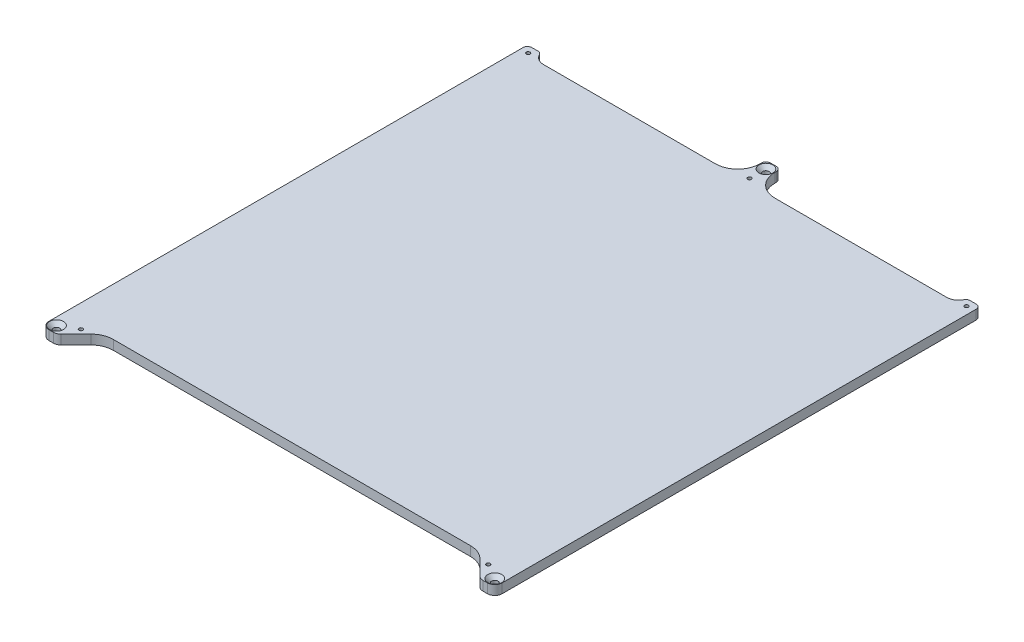
from build123d import *

# Parameters (mm, degrees)
SKETCH1_W                      = 305
SKETCH1_H                      = 327
BOSS_EXTRUDE1_DEPTH            = 6.35
CUT_EXTRUDE1_DEPTH             = 7.35
SKETCH3_W                      = 10
SKETCH3_H                      = 6.35
BOSS_EXTRUDE2_DEPTH            = 19
SKETCH4_W                      = 253
SKETCH4_H                      = 16
CUT_EXTRUDE2_DEPTH             = 7.35
DRAFT1_ANGLE                   = 45
F_4_3_4_3_DIAMETER_HOLE1_D     = 4.3
F_2_5_2_5_DIAMETER_HOLE1_D     = 2.5
F_2_5_2_5_DIAMETER_HOLE1_DEPTH = 6.35
CHAMFER1_SIZE                  = 2.55
FILLET1_R                      = 3
FILLET2_R                      = 5
FILLET3_R                      = 15


with BuildPart() as part:
    # Sketch1 → Boss-Extrude1 (new body)
    with BuildSketch(Plane(origin=(0, 6.35, 0), x_dir=(1, 0, 0), z_dir=(0, 1, 0))):
        with Locations((0, -5)):
            Rectangle(SKETCH1_W, SKETCH1_H)
    extrude(amount=-BOSS_EXTRUDE1_DEPTH)

    # Sketch2 → Cut-Extrude1 (cut, through all)
    with BuildSketch(Plane(origin=(0, 6.35, 0), x_dir=(-1, 0, 0), z_dir=(0, 1, 0))):
        with BuildLine():
            Line((-143.448007721, -158.5), (143.448007721, -158.5))
            ThreePointArc((143.448007721, -158.5), (140.601020514, -154.17544468), (135.702041029, -152.5))
            Line((135.702041029, -152.5), (-135.702041029, -152.5))
            ThreePointArc((-135.702041029, -152.5), (-140.601020514, -154.17544468), (-143.448007721, -158.5))
        make_face()
    extrude(amount=-CUT_EXTRUDE1_DEPTH, mode=Mode.SUBTRACT)

    # Sketch3 → Boss-Extrude2 (add)
    with BuildSketch(Plane(origin=(0, 0, -152.5), x_dir=(-1, 0, 0), z_dir=(0, 0, -1))):
        with Locations((0, 3.175)):
            Rectangle(SKETCH3_W, SKETCH3_H)
    extrude(amount=BOSS_EXTRUDE2_DEPTH)

    # Sketch4 → Cut-Extrude2 (cut, through all)
    with BuildSketch(Plane.XZ):
        with Locations((0, 160.5)):
            Rectangle(SKETCH4_W, SKETCH4_H)
    extrude(amount=-CUT_EXTRUDE2_DEPTH, mode=Mode.SUBTRACT)

    # Draft1
    draft1_faces = [part.faces().sort_by_distance(p)[0] for p in [
        (-126.5, 3.175, 160.5),
        (126.5, 3.175, 160.5),
    ]]
    draft(draft1_faces, Plane(origin=(-126.5, 6.35, 152.5), x_dir=(1, 0, 0), z_dir=(0, 0, 1)), DRAFT1_ANGLE)

    # Ø4.3 (4.3) Diameter Hole1 (through all)
    with Locations(Plane(origin=(0, 6.35, 0), x_dir=(1, 0, 0), z_dir=(0, 1, 0))):
        with Locations((0, 166.5), (-147.5, -163.5), (147.5, -163.5)):
            Hole(F_4_3_4_3_DIAMETER_HOLE1_D / 2)

    # Ø2.5 (2.5) Diameter Hole1
    with Locations(Plane(origin=(0, 0, 0), x_dir=(-1, 0, 0), z_dir=(0, -1, 0))):
        with Locations((147.5, 154), (-147.5, 154), (-137.107695155, -157.5), (137.107695155, -157.5), (0, 155.5)):
            Hole(F_2_5_2_5_DIAMETER_HOLE1_D / 2, depth=F_2_5_2_5_DIAMETER_HOLE1_DEPTH)

    # Chamfer1
    chamfer1_edges = [part.edges().sort_by_distance(p)[0] for p in [
        (149.65, 6.35, 163.5),
        (-145.35, 6.35, 163.5),
        (2.15, 6.35, -166.5),
    ]]
    chamfer(chamfer1_edges, length=CHAMFER1_SIZE)

    # Fillet1
    fillet1_edges = [part.edges().sort_by_distance(p)[0] for p in [
        (143.448007721, 3.175, -158.5),
        (-143.448007721, 3.175, -158.5),
        (-5, 3.175, -171.5),
        (5, 3.175, -171.5),
        (-152.5, 3.175, -158.5),
        (152.5, 3.175, -158.5),
    ]]
    fillet(fillet1_edges, radius=FILLET1_R)

    # Fillet2
    fillet2_edges = [part.edges().sort_by_distance(p)[0] for p in [
        (-142.5, 3.175, 168.5),
        (142.5, 3.175, 168.5),
        (152.5, 3.175, 168.5),
        (-152.5, 3.175, 168.5),
    ]]
    fillet(fillet2_edges, radius=FILLET2_R)

    # Fillet3
    fillet3_edges = [part.edges().sort_by_distance(p)[0] for p in [
        (-5, 3.175, -152.5),
        (5, 3.175, -152.5),
        (126.5, 3.175, 152.5),
        (-126.5, 3.175, 152.5),
    ]]
    fillet(fillet3_edges, radius=FILLET3_R)


solid = part.part
